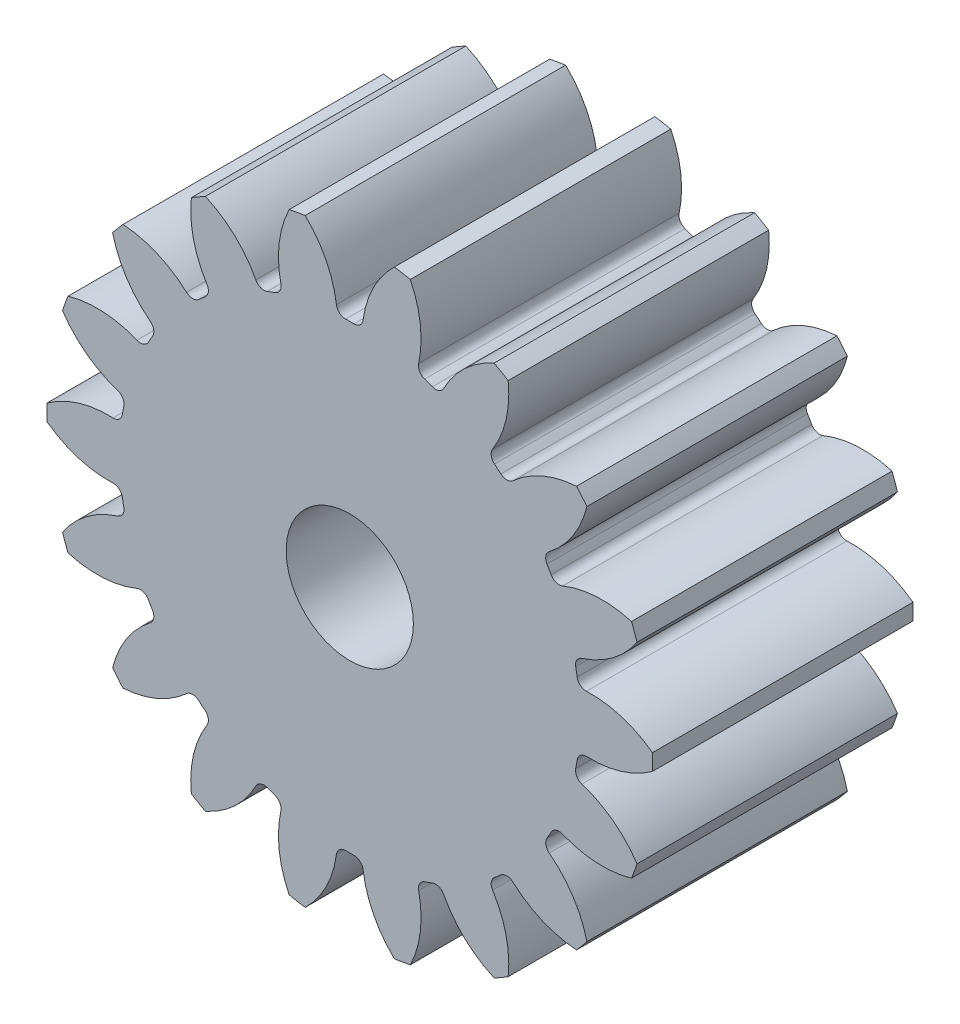
from build123d import *

# Parameters (mm, degrees)
SKETCH1_R                = 5
BOSS_EXTRUDE1_DEPTH      = 2.15
CUT_EXTRUDE1_DEPTH       = 8.39070362
FILLET1_R                = 0.15
CIRPATTERN1_COUNT        = 18
FILLET1_OF_CIRPATTERN1_R = 0.15
CUT_EXTRUDE2_DEPTH       = 8.353950974
CUT_EXTRUDE2_DEPTH_BACK  = 8.353950974
SKETCH2_R                = 1.05


with BuildPart() as part:
    # Sketch1 → Boss-Extrude1 (new, symmetric)
    with BuildSketch(Plane.XY):
        Circle(SKETCH1_R)
    extrude(amount=BOSS_EXTRUDE1_DEPTH, both=True)

    # Gear Profile → Cut-Extrude1 (cut, symmetric)
    with BuildSketch(Plane.XY):
        with BuildLine():
            ThreePointArc((-1.362608405, 5.328536228), (-0.551207912, 4.737388407), (-0.206930556, 3.794361573))
            ThreePointArc((-0.206930556, 3.794361573), (0, 3.8), (0.206930556, 3.794361573))
            ThreePointArc((0.206930556, 3.794361573), (0.551207912, 4.737388407), (1.362608405, 5.328536228))
            ThreePointArc((1.362608405, 5.328536228), (0, 5.5), (-1.362608405, 5.328536228))
        make_face()
    cut_extrude1 = extrude(amount=CUT_EXTRUDE1_DEPTH, both=True, mode=Mode.SUBTRACT)

    # Fillet1
    fillet1_edges = [part.edges().sort_by_distance(p)[0] for p in [
        (0.206930556, 3.794361573, 0),
        (-0.206930556, 3.794361573, 0),
    ]]
    fillet(fillet1_edges, radius=FILLET1_R)

    # CirPattern1: Cut-Extrude1 ×18 about axis
    cirpattern1_axis = Axis((0, 0, -2.75), (0, 0, 1))
    for i in range(1, CIRPATTERN1_COUNT):
        add(cut_extrude1.rotate(cirpattern1_axis, i * 360 / CIRPATTERN1_COUNT), mode=Mode.SUBTRACT)

    # Fillet1 of CirPattern1
    fillet1_of_cirpattern1_edges = [part.edges().sort_by_distance(p)[0] for p in [
        (-1.103296972, 3.636307989, 0),
        (-1.492199206, 3.494759152, 0),
        (-2.280450603, 3.039661996, 0),
        (-2.597486609, 2.7736372, 0),
        (-3.182548235, 2.076387905, 0),
        (-3.389478791, 1.717973668, 0),
        (-3.700783581, 0.862670789, 0),
        (-3.772649809, 0.455097156, 0),
        (-3.772649809, -0.455097156, 0),
        (-3.700783581, -0.862670789, 0),
        (-3.389478791, -1.717973668, 0),
        (-3.182548235, -2.076387905, 0),
        (-2.597486609, -2.7736372, 0),
        (-2.280450603, -3.039661996, 0),
        (-1.492199206, -3.494759152, 0),
        (-1.103296972, -3.636307989, 0),
        (-0.206930556, -3.794361573, 0),
        (0.206930556, -3.794361573, 0),
        (1.103296972, -3.636307989, 0),
        (1.492199206, -3.494759152, 0),
        (2.280450603, -3.039661996, 0),
        (2.597486609, -2.7736372, 0),
        (3.182548235, -2.076387905, 0),
        (3.389478791, -1.717973668, 0),
        (3.700783581, -0.862670789, 0),
        (3.772649809, -0.455097156, 0),
        (3.772649809, 0.455097156, 0),
        (3.700783581, 0.862670789, 0),
        (3.389478791, 1.717973668, 0),
        (3.182548235, 2.076387905, 0),
        (2.597486609, 2.7736372, 0),
        (2.280450603, 3.039661996, 0),
        (1.492199206, 3.494759152, 0),
        (1.103296972, 3.636307989, 0),
    ]]
    fillet(fillet1_of_cirpattern1_edges, radius=FILLET1_OF_CIRPATTERN1_R)

    # Sketch2 → Cut-Extrude2 (cut, two sides: drawn at the far end of the back side and taken through both)
    with BuildSketch(Plane.XY.offset(-CUT_EXTRUDE2_DEPTH_BACK)):
        Circle(SKETCH2_R)
    extrude(amount=CUT_EXTRUDE2_DEPTH + CUT_EXTRUDE2_DEPTH_BACK, mode=Mode.SUBTRACT)


solid = part.part
